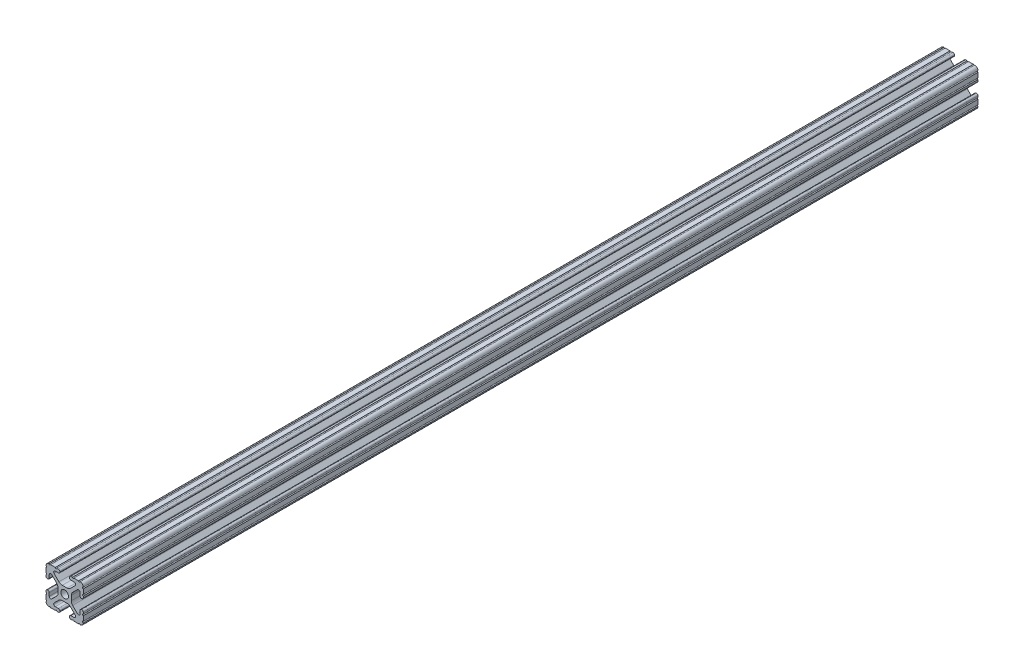
from build123d import *

# Parameters (mm, degrees)
SKETCH1_R           = 2.6035
BOSS_EXTRUDE1_DEPTH = 304.8


with BuildPart() as part:
    # Sketch1 → Boss-Extrude1 (new body, symmetric)
    with BuildSketch(Plane.XY):
        with BuildLine():
            Line((-7.179650497, -8.645192506), (-3.952270251, -5.423690499))
            ThreePointArc((-3.952270251, -5.423690499), (-2.922936451, -4.736929036), (-1.709253557, -4.4958))
            Line((-1.709253557, -4.4958), (1.709253557, -4.4958))
            ThreePointArc((1.709253557, -4.4958), (2.922936451, -4.736929036), (3.952270251, -5.423690499))
            Line((3.952270251, -5.423690499), (7.179650497, -8.645192506))
            ThreePointArc((7.179650497, -8.645192506), (7.41473083, -9.822813117), (6.416408329, -10.4902))
            Line((6.416408329, -10.4902), (4.287512407, -10.4902))
            ThreePointArc((4.287512407, -10.4902), (3.54574862, -10.79744862), (3.2385, -11.539212407))
            Line((3.2385, -11.539212407), (3.2385, -11.650987593))
            ThreePointArc((3.2385, -11.650987593), (3.54574862, -12.39275138), (4.287512407, -12.7))
            Line((4.287512407, -12.7), (5.317126718, -12.7))
            ThreePointArc((5.317126718, -12.7), (5.825126718, -12.192), (6.333126718, -12.7))
            Line((6.333126718, -12.7), (9.550443118, -12.7))
            ThreePointArc((9.550443118, -12.7), (10.058366869, -12.192000006), (10.566443095, -12.699847501))
            ThreePointArc((10.566443095, -12.699847501), (12.082537762, -12.08250727), (12.699846982, -10.566399977))
            ThreePointArc((12.699846982, -10.566399977), (12.192000006, -10.058323491), (12.7, -9.5504))
            Line((12.7, -9.5504), (12.7, -6.3330836))
            ThreePointArc((12.7, -6.3330836), (12.192, -5.8250836), (12.7, -5.3170836))
            Line((12.7, -5.3170836), (12.7, -4.287469289))
            ThreePointArc((12.7, -4.287469289), (12.39275138, -3.545705502), (11.650987593, -3.238456882))
            Line((11.650987593, -3.238456882), (11.539212407, -3.238456882))
            ThreePointArc((11.539212407, -3.238456882), (10.79744862, -3.545705502), (10.4902, -4.287469289))
            Line((10.4902, -4.287469289), (10.4902, -6.402089023))
            ThreePointArc((10.4902, -6.402089023), (9.856505071, -7.351067942), (8.737131347, -7.129408934))
            Line((8.737131347, -7.129408934), (5.441005833, -3.840816462))
            ThreePointArc((5.441005833, -3.840816462), (4.750877967, -2.809883091), (4.5085, -1.593185507))
            Line((4.5085, -1.593185507), (4.5085, 1.593185507))
            ThreePointArc((4.5085, 1.593185507), (4.750877967, 2.809883091), (5.441005833, 3.840816462))
            Line((5.441005833, 3.840816462), (8.737131347, 7.129408934))
            ThreePointArc((8.737131347, 7.129408934), (9.856505071, 7.351067942), (10.4902, 6.402089023))
            Line((10.4902, 6.402089023), (10.4902, 4.287469289))
            ThreePointArc((10.4902, 4.287469289), (10.79744862, 3.545705502), (11.539212407, 3.238456882))
            Line((11.539212407, 3.238456882), (11.650987593, 3.238456882))
            ThreePointArc((11.650987593, 3.238456882), (12.39275138, 3.545705502), (12.7, 4.287469289))
            Line((12.7, 4.287469289), (12.7, 5.3170836))
            ThreePointArc((12.7, 5.3170836), (12.192, 5.8250836), (12.7, 6.3330836))
            Line((12.7, 6.3330836), (12.7, 9.5504))
            ThreePointArc((12.7, 9.5504), (12.192000006, 10.058323491), (12.699846982, 10.566399977))
            ThreePointArc((12.699846982, 10.566399977), (12.082537762, 12.08250727), (10.566443095, 12.699847501))
            ThreePointArc((10.566443095, 12.699847501), (10.058366869, 12.192000006), (9.550443118, 12.7))
            Line((9.550443118, 12.7), (6.333126718, 12.7))
            ThreePointArc((6.333126718, 12.7), (5.825126718, 12.192), (5.317126718, 12.7))
            Line((5.317126718, 12.7), (4.287512407, 12.7))
            ThreePointArc((4.287512407, 12.7), (3.54574862, 12.39275138), (3.2385, 11.650987593))
            Line((3.2385, 11.650987593), (3.2385, 11.539212407))
            ThreePointArc((3.2385, 11.539212407), (3.54574862, 10.79744862), (4.287512407, 10.4902))
            Line((4.287512407, 10.4902), (6.476788598, 10.4902))
            ThreePointArc((6.476788598, 10.4902), (7.432222385, 9.85140422), (7.207036008, 8.724370562))
            Line((7.207036008, 8.724370562), (3.898272566, 5.423169045))
            ThreePointArc((3.898272566, 5.423169045), (2.869120213, 4.736787962), (1.655778399, 4.4958))
            Line((1.655778399, 4.4958), (-1.655778399, 4.4958))
            ThreePointArc((-1.655778399, 4.4958), (-2.869120213, 4.736787962), (-3.898272566, 5.423169045))
            Line((-3.898272566, 5.423169045), (-7.207036008, 8.724370562))
            ThreePointArc((-7.207036008, 8.724370562), (-7.432222385, 9.85140422), (-6.476788598, 10.4902))
            Line((-6.476788598, 10.4902), (-4.287512407, 10.4902))
            ThreePointArc((-4.287512407, 10.4902), (-3.54574862, 10.79744862), (-3.2385, 11.539212407))
            Line((-3.2385, 11.539212407), (-3.2385, 11.650987593))
            ThreePointArc((-3.2385, 11.650987593), (-3.54574862, 12.39275138), (-4.287512407, 12.7))
            Line((-4.287512407, 12.7), (-5.317126718, 12.7))
            ThreePointArc((-5.317126718, 12.7), (-5.825126718, 12.192), (-6.333126718, 12.7))
            Line((-6.333126718, 12.7), (-9.550443118, 12.7))
            ThreePointArc((-9.550443118, 12.7), (-10.058366869, 12.192000006), (-10.566443095, 12.699847501))
            ThreePointArc((-10.566443095, 12.699847501), (-12.082537762, 12.08250727), (-12.699846982, 10.566399977))
            ThreePointArc((-12.699846982, 10.566399977), (-12.192000006, 10.058323491), (-12.7, 9.5504))
            Line((-12.7, 9.5504), (-12.7, 6.3330836))
            ThreePointArc((-12.7, 6.3330836), (-12.192, 5.8250836), (-12.7, 5.3170836))
            Line((-12.7, 5.3170836), (-12.7, 4.287469289))
            ThreePointArc((-12.7, 4.287469289), (-12.39275138, 3.545705502), (-11.650987593, 3.238456882))
            Line((-11.650987593, 3.238456882), (-11.539212407, 3.238456882))
            ThreePointArc((-11.539212407, 3.238456882), (-10.79744862, 3.545705502), (-10.4902, 4.287469289))
            Line((-10.4902, 4.287469289), (-10.4902, 6.402089023))
            ThreePointArc((-10.4902, 6.402089023), (-9.856505071, 7.351067942), (-8.737131347, 7.129408934))
            Line((-8.737131347, 7.129408934), (-5.441005833, 3.840816462))
            ThreePointArc((-5.441005833, 3.840816462), (-4.750877967, 2.809883091), (-4.5085, 1.593185507))
            Line((-4.5085, 1.593185507), (-4.5085, -1.593185507))
            ThreePointArc((-4.5085, -1.593185507), (-4.750877967, -2.809883091), (-5.441005833, -3.840816462))
            Line((-5.441005833, -3.840816462), (-8.737131347, -7.129408934))
            ThreePointArc((-8.737131347, -7.129408934), (-9.856505071, -7.351067942), (-10.4902, -6.402089023))
            Line((-10.4902, -6.402089023), (-10.4902, -4.287469289))
            ThreePointArc((-10.4902, -4.287469289), (-10.79744862, -3.545705502), (-11.539212407, -3.238456882))
            Line((-11.539212407, -3.238456882), (-11.650987593, -3.238456882))
            ThreePointArc((-11.650987593, -3.238456882), (-12.39275138, -3.545705502), (-12.7, -4.287469289))
            Line((-12.7, -4.287469289), (-12.7, -5.3170836))
            ThreePointArc((-12.7, -5.3170836), (-12.192, -5.8250836), (-12.7, -6.3330836))
            Line((-12.7, -6.3330836), (-12.7, -9.5504))
            ThreePointArc((-12.7, -9.5504), (-12.192000006, -10.058323491), (-12.699846982, -10.566399977))
            ThreePointArc((-12.699846982, -10.566399977), (-12.082537762, -12.08250727), (-10.566443095, -12.699847501))
            ThreePointArc((-10.566443095, -12.699847501), (-10.058366869, -12.192000006), (-9.550443118, -12.7))
            Line((-9.550443118, -12.7), (-6.333126718, -12.7))
            ThreePointArc((-6.333126718, -12.7), (-5.825126718, -12.192), (-5.317126718, -12.7))
            Line((-5.317126718, -12.7), (-4.287512407, -12.7))
            ThreePointArc((-4.287512407, -12.7), (-3.54574862, -12.39275138), (-3.2385, -11.650987593))
            Line((-3.2385, -11.650987593), (-3.2385, -11.539212407))
            ThreePointArc((-3.2385, -11.539212407), (-3.54574862, -10.79744862), (-4.287512407, -10.4902))
            Line((-4.287512407, -10.4902), (-6.416408329, -10.4902))
            ThreePointArc((-6.416408329, -10.4902), (-7.41473083, -9.822813117), (-7.179650497, -8.645192506))
        make_face()
        Circle(SKETCH1_R, mode=Mode.SUBTRACT)
    extrude(amount=BOSS_EXTRUDE1_DEPTH, both=True)


solid = part.part
